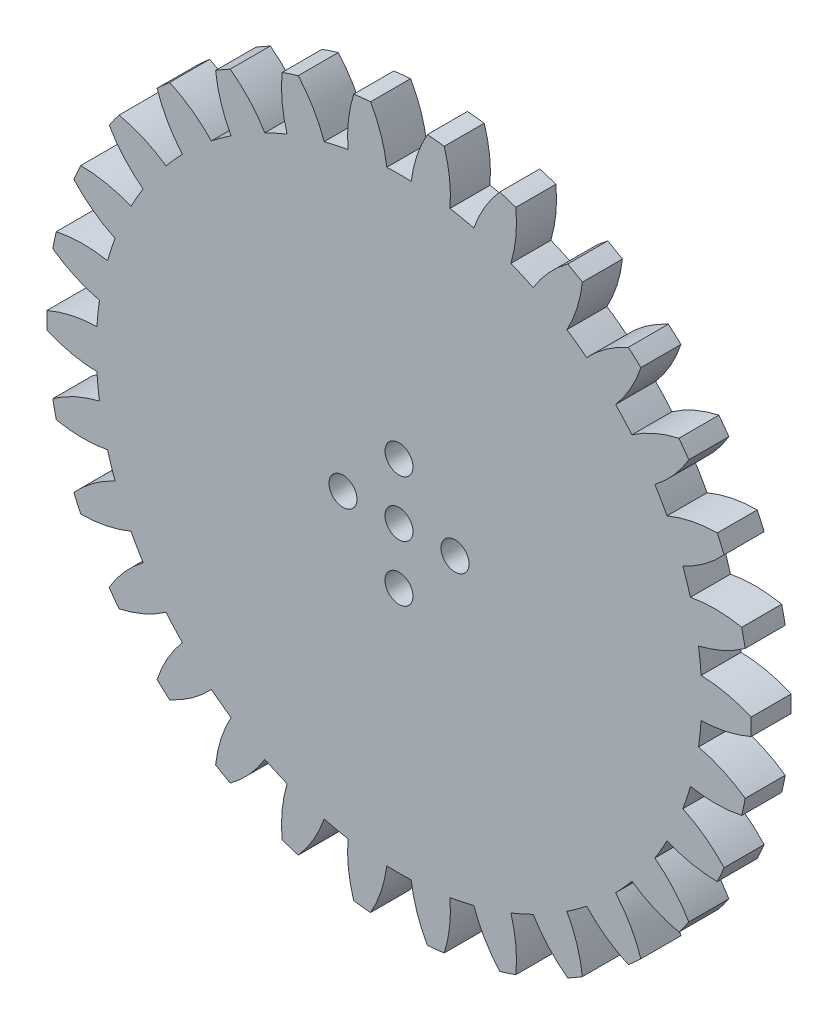
from build123d import *

# Parameters (mm, degrees)
SKETCH_1_R      = 1.75
EXTRUDE_1_DEPTH = 5
SCALE_1_SCALE   = 0.95


with BuildPart() as part:
    # 草图1 → 凸台-拉伸1 (new body)
    with BuildSketch(Plane.XY):
        with BuildLine():
            ThreePointArc((-43.98730465, -1.056896208), (-40.927651292, -2.051995365), (-37.733051967, -2.434403732))
            ThreePointArc((-37.733051967, -2.434403732), (-37.604364647, -3.952377989), (-37.414635246, -5.463936465))
            ThreePointArc((-37.414635246, -5.463936465), (-40.459917741, -6.502182838), (-43.245817584, -8.111674394))
            ThreePointArc((-43.245817584, -8.111674394), (-43.038494432, -9.148114396), (-42.806335429, -10.179275375))
            ThreePointArc((-42.806335429, -10.179275375), (-39.606650089, -10.516491524), (-36.402353254, -10.226348803))
            ThreePointArc((-36.402353254, -10.226348803), (-35.960873466, -11.684396083), (-35.461019429, -13.123476419))
            ThreePointArc((-35.461019429, -13.123476419), (-38.223891636, -14.772184451), (-40.614280773, -16.925725901))
            ThreePointArc((-40.614280773, -16.925725901), (-40.196000136, -17.896412295), (-39.754523941, -18.856771362))
            ThreePointArc((-39.754523941, -18.856771362), (-36.554648223, -18.52136654), (-33.480697026, -17.571353361))
            ThreePointArc((-33.480697026, -17.571353361), (-32.745719555, -18.90575), (-31.957586902, -20.20945748))
            ThreePointArc((-31.957586902, -20.20945748), (-34.317298048, -22.396570718), (-36.207705003, -25.000041968))
            ThreePointArc((-36.207705003, -25.000041968), (-35.596747752, -25.862551101), (-34.965248994, -26.710135956))
            ThreePointArc((-34.965248994, -26.710135956), (-31.905032822, -25.716768963), (-29.095773679, -24.14840546))
            ThreePointArc((-29.095773679, -24.14840546), (-28.099420569, -25.300831922), (-27.057454478, -26.412188274))
            ThreePointArc((-27.057454478, -26.412188274), (-28.910873863, -29.042119374), (-30.218678781, -31.981736237))
            ThreePointArc((-30.218678781, -31.981736237), (-29.44174668, -32.698372321), (-28.647824884, -33.396139438))
            ThreePointArc((-28.647824884, -33.396139438), (-25.861014388, -31.788225179), (-23.439225406, -29.670056364))
            ThreePointArc((-23.439225406, -29.670056364), (-22.225042067, -30.590146083), (-20.974781458, -31.4605797))
            ThreePointArc((-20.974781458, -31.4605797), (-22.24090576, -34.418388053), (-22.908951291, -37.565675167))
            ThreePointArc((-22.908951291, -37.565675167), (-22, -38.105117767), (-21.07835336, -38.622571375))
            ThreePointArc((-21.07835336, -38.622571375), (-18.686745531, -36.470383418), (-16.758270509, -33.894983431))
            ThreePointArc((-16.758270509, -33.894983431), (-15.37932258, -34.542524072), (-13.97540984, -35.133992828))
            ThreePointArc((-13.97540984, -35.133992828), (-14.598903352, -38.290408018), (-14.5979927, -41.507813832))
            ThreePointArc((-14.5979927, -41.507813832), (-13.596747752, -41.846486717), (-12.587656648, -42.161011612))
            ThreePointArc((-12.587656648, -42.161011612), (-10.695776226, -39.558610898), (-9.344898775, -36.638537077))
            ThreePointArc((-9.344898775, -36.638537077), (-7.861452897, -36.985228005), (-6.36524575, -37.271881879))
            ThreePointArc((-6.36524575, -37.271881879), (-6.318858814, -40.488953413), (-5.649031779, -43.635861857))
            ThreePointArc((-5.649031779, -43.635861857), (-4.599252384, -43.758963396), (-3.546818938, -43.85681333))
            ThreePointArc((-3.546818938, -43.85681333), (-2.237350175, -40.917937258), (-1.523110123, -37.780810841))
            ThreePointArc((-1.523110123, -37.780810841), (0, -37.8115), (1.523110123, -37.780810841))
            ThreePointArc((1.523110123, -37.780810841), (2.237350175, -40.917937258), (3.546818938, -43.85681333))
            ThreePointArc((3.546818938, -43.85681333), (4.599252384, -43.758963396), (5.649031779, -43.635861857))
            ThreePointArc((5.649031779, -43.635861857), (6.318858814, -40.488953413), (6.36524575, -37.271881879))
            ThreePointArc((6.36524575, -37.271881879), (7.861452897, -36.985228005), (9.344898775, -36.638537077))
            ThreePointArc((9.344898775, -36.638537077), (10.695776226, -39.558610898), (12.587656648, -42.161011612))
            ThreePointArc((12.587656648, -42.161011612), (13.596747752, -41.846486717), (14.5979927, -41.507813832))
            ThreePointArc((14.5979927, -41.507813832), (14.598903352, -38.290408018), (13.97540984, -35.133992828))
            ThreePointArc((13.97540984, -35.133992828), (15.37932258, -34.542524072), (16.758270509, -33.894983431))
            ThreePointArc((16.758270509, -33.894983431), (18.686745531, -36.470383418), (21.07835336, -38.622571375))
            ThreePointArc((21.07835336, -38.622571375), (22, -38.105117767), (22.908951291, -37.565675167))
            ThreePointArc((22.908951291, -37.565675167), (22.24090576, -34.418388053), (20.974781458, -31.4605797))
            ThreePointArc((20.974781458, -31.4605797), (22.225042067, -30.590146083), (23.439225406, -29.670056364))
            ThreePointArc((23.439225406, -29.670056364), (25.861014388, -31.788225179), (28.647824884, -33.396139438))
            ThreePointArc((28.647824884, -33.396139438), (29.44174668, -32.698372321), (30.218678781, -31.981736237))
            ThreePointArc((30.218678781, -31.981736237), (28.910873863, -29.042119374), (27.057454478, -26.412188274))
            ThreePointArc((27.057454478, -26.412188274), (28.099420569, -25.300831922), (29.095773679, -24.14840546))
            ThreePointArc((29.095773679, -24.14840546), (31.905032822, -25.716768963), (34.965248994, -26.710135956))
            ThreePointArc((34.965248994, -26.710135956), (35.596747752, -25.862551101), (36.207705003, -25.000041968))
            ThreePointArc((36.207705003, -25.000041968), (34.317298048, -22.396570718), (31.957586902, -20.20945748))
            ThreePointArc((31.957586902, -20.20945748), (32.745719555, -18.90575), (33.480697026, -17.571353361))
            ThreePointArc((33.480697026, -17.571353361), (36.554648223, -18.52136654), (39.754523941, -18.856771362))
            ThreePointArc((39.754523941, -18.856771362), (40.196000136, -17.896412295), (40.614280773, -16.925725901))
            ThreePointArc((40.614280773, -16.925725901), (38.223891636, -14.772184451), (35.461019429, -13.123476419))
            ThreePointArc((35.461019429, -13.123476419), (35.960873466, -11.684396083), (36.402353254, -10.226348803))
            ThreePointArc((36.402353254, -10.226348803), (39.606650089, -10.516491524), (42.806335429, -10.179275375))
            ThreePointArc((42.806335429, -10.179275375), (43.038494432, -9.148114396), (43.245817584, -8.111674394))
            ThreePointArc((43.245817584, -8.111674394), (40.459917741, -6.502182838), (37.414635246, -5.463936465))
            ThreePointArc((37.414635246, -5.463936465), (37.604364647, -3.952377989), (37.733051967, -2.434403732))
            ThreePointArc((37.733051967, -2.434403732), (40.927651292, -2.051995365), (43.98730465, -1.056896208))
            ThreePointArc((43.98730465, -1.056896208), (44, 0), (43.98730465, 1.056896208))
            ThreePointArc((43.98730465, 1.056896208), (40.927651292, 2.051995365), (37.733051967, 2.434403732))
            ThreePointArc((37.733051967, 2.434403732), (37.604364647, 3.952377989), (37.414635246, 5.463936465))
            ThreePointArc((37.414635246, 5.463936465), (40.459917741, 6.502182838), (43.245817584, 8.111674394))
            ThreePointArc((43.245817584, 8.111674394), (43.038494432, 9.148114396), (42.806335429, 10.179275375))
            ThreePointArc((42.806335429, 10.179275375), (39.606650089, 10.516491524), (36.402353254, 10.226348803))
            ThreePointArc((36.402353254, 10.226348803), (35.960873466, 11.684396083), (35.461019429, 13.123476419))
            ThreePointArc((35.461019429, 13.123476419), (38.223891636, 14.772184451), (40.614280773, 16.925725901))
            ThreePointArc((40.614280773, 16.925725901), (40.196000136, 17.896412295), (39.754523941, 18.856771362))
            ThreePointArc((39.754523941, 18.856771362), (36.554648223, 18.52136654), (33.480697026, 17.571353361))
            ThreePointArc((33.480697026, 17.571353361), (32.745719555, 18.90575), (31.957586902, 20.20945748))
            ThreePointArc((31.957586902, 20.20945748), (34.317298048, 22.396570718), (36.207705003, 25.000041968))
            ThreePointArc((36.207705003, 25.000041968), (35.596747752, 25.862551101), (34.965248994, 26.710135956))
            ThreePointArc((34.965248994, 26.710135956), (31.905032822, 25.716768963), (29.095773679, 24.14840546))
            ThreePointArc((29.095773679, 24.14840546), (28.099420569, 25.300831922), (27.057454478, 26.412188274))
            ThreePointArc((27.057454478, 26.412188274), (28.910873863, 29.042119374), (30.218678781, 31.981736237))
            ThreePointArc((30.218678781, 31.981736237), (29.44174668, 32.698372321), (28.647824884, 33.396139438))
            ThreePointArc((28.647824884, 33.396139438), (25.861014388, 31.788225179), (23.439225406, 29.670056364))
            ThreePointArc((23.439225406, 29.670056364), (22.225042067, 30.590146083), (20.974781458, 31.4605797))
            ThreePointArc((20.974781458, 31.4605797), (22.24090576, 34.418388053), (22.908951291, 37.565675167))
            ThreePointArc((22.908951291, 37.565675167), (22, 38.105117767), (21.07835336, 38.622571375))
            ThreePointArc((21.07835336, 38.622571375), (18.686745531, 36.470383418), (16.758270509, 33.894983431))
            ThreePointArc((16.758270509, 33.894983431), (15.37932258, 34.542524072), (13.97540984, 35.133992828))
            ThreePointArc((13.97540984, 35.133992828), (14.598903352, 38.290408018), (14.5979927, 41.507813832))
            ThreePointArc((14.5979927, 41.507813832), (13.596747752, 41.846486717), (12.587656648, 42.161011612))
            ThreePointArc((12.587656648, 42.161011612), (10.695776226, 39.558610898), (9.344898775, 36.638537077))
            ThreePointArc((9.344898775, 36.638537077), (7.861452897, 36.985228005), (6.36524575, 37.271881879))
            ThreePointArc((6.36524575, 37.271881879), (6.318858814, 40.488953413), (5.649031779, 43.635861857))
            ThreePointArc((5.649031779, 43.635861857), (4.599252384, 43.758963396), (3.546818938, 43.85681333))
            ThreePointArc((3.546818938, 43.85681333), (2.237350175, 40.917937258), (1.523110123, 37.780810841))
            ThreePointArc((1.523110123, 37.780810841), (0, 37.8115), (-1.523110123, 37.780810841))
            ThreePointArc((-1.523110123, 37.780810841), (-2.237350175, 40.917937258), (-3.546818938, 43.85681333))
            ThreePointArc((-3.546818938, 43.85681333), (-4.599252384, 43.758963396), (-5.649031779, 43.635861857))
            ThreePointArc((-5.649031779, 43.635861857), (-6.318858814, 40.488953413), (-6.36524575, 37.271881879))
            ThreePointArc((-6.36524575, 37.271881879), (-7.861452897, 36.985228005), (-9.344898775, 36.638537077))
            ThreePointArc((-9.344898775, 36.638537077), (-10.695776226, 39.558610898), (-12.587656648, 42.161011612))
            ThreePointArc((-12.587656648, 42.161011612), (-13.596747752, 41.846486717), (-14.5979927, 41.507813832))
            ThreePointArc((-14.5979927, 41.507813832), (-14.598903352, 38.290408018), (-13.97540984, 35.133992828))
            ThreePointArc((-13.97540984, 35.133992828), (-15.37932258, 34.542524072), (-16.758270509, 33.894983431))
            ThreePointArc((-16.758270509, 33.894983431), (-18.686745531, 36.470383418), (-21.07835336, 38.622571375))
            ThreePointArc((-21.07835336, 38.622571375), (-22, 38.105117767), (-22.908951291, 37.565675167))
            ThreePointArc((-22.908951291, 37.565675167), (-22.24090576, 34.418388053), (-20.974781458, 31.4605797))
            ThreePointArc((-20.974781458, 31.4605797), (-22.225042067, 30.590146083), (-23.439225406, 29.670056364))
            ThreePointArc((-23.439225406, 29.670056364), (-25.861014388, 31.788225179), (-28.647824884, 33.396139438))
            ThreePointArc((-28.647824884, 33.396139438), (-29.44174668, 32.698372321), (-30.218678781, 31.981736237))
            ThreePointArc((-30.218678781, 31.981736237), (-28.910873863, 29.042119374), (-27.057454478, 26.412188274))
            ThreePointArc((-27.057454478, 26.412188274), (-28.099420569, 25.300831922), (-29.095773679, 24.14840546))
            ThreePointArc((-29.095773679, 24.14840546), (-31.905032822, 25.716768963), (-34.965248994, 26.710135956))
            ThreePointArc((-34.965248994, 26.710135956), (-35.596747752, 25.862551101), (-36.207705003, 25.000041968))
            ThreePointArc((-36.207705003, 25.000041968), (-34.317298048, 22.396570718), (-31.957586902, 20.20945748))
            ThreePointArc((-31.957586902, 20.20945748), (-32.745719555, 18.90575), (-33.480697026, 17.571353361))
            ThreePointArc((-33.480697026, 17.571353361), (-36.554648223, 18.52136654), (-39.754523941, 18.856771362))
            ThreePointArc((-39.754523941, 18.856771362), (-40.196000136, 17.896412295), (-40.614280773, 16.925725901))
            ThreePointArc((-40.614280773, 16.925725901), (-38.223891636, 14.772184451), (-35.461019429, 13.123476419))
            ThreePointArc((-35.461019429, 13.123476419), (-35.960873466, 11.684396083), (-36.402353254, 10.226348803))
            ThreePointArc((-36.402353254, 10.226348803), (-39.606650089, 10.516491524), (-42.806335429, 10.179275375))
            ThreePointArc((-42.806335429, 10.179275375), (-43.038494432, 9.148114396), (-43.245817584, 8.111674394))
            ThreePointArc((-43.245817584, 8.111674394), (-40.459917741, 6.502182838), (-37.414635246, 5.463936465))
            ThreePointArc((-37.414635246, 5.463936465), (-37.604364647, 3.952377989), (-37.733051967, 2.434403732))
            ThreePointArc((-37.733051967, 2.434403732), (-40.927651292, 2.051995365), (-43.98730465, 1.056896208))
            ThreePointArc((-43.98730465, 1.056896208), (-44, 0), (-43.98730465, -1.056896208))
        make_face()
        with Locations((0, 7)):
            Circle(SKETCH_1_R, mode=Mode.SUBTRACT)
        with Locations((7, 0)):
            Circle(SKETCH_1_R, mode=Mode.SUBTRACT)
        with Locations((0, -7)):
            Circle(SKETCH_1_R, mode=Mode.SUBTRACT)
        with Locations((-7, 0)):
            Circle(SKETCH_1_R, mode=Mode.SUBTRACT)
        Circle(SKETCH_1_R, mode=Mode.SUBTRACT)
    extrude(amount=EXTRUDE_1_DEPTH)


with BuildPart() as part_1:
    # 缩放比例1: scaled about (0, 0, 2.5)
    add(part.part.scale(SCALE_1_SCALE).moved(Location((0, 0, 0.125))))


solid = part_1.part
